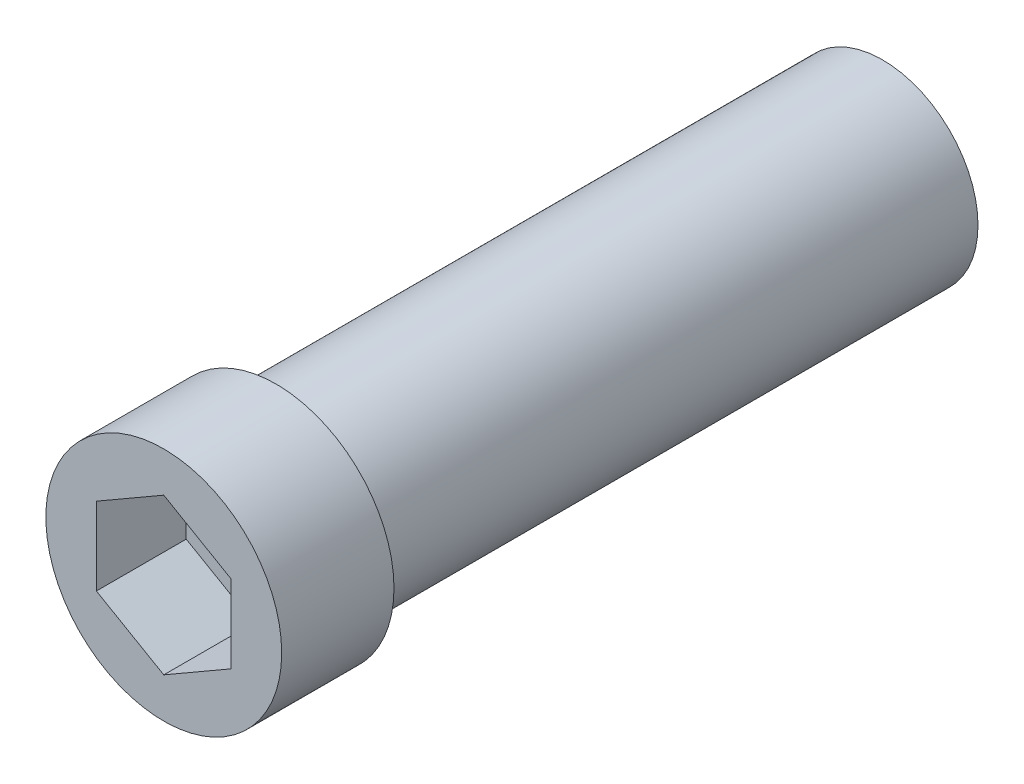
from build123d import *

# Parameters (mm, degrees)
SKETCH1_R           = 4.25
BOSS_EXTRUDE1_DEPTH = 27
SKETCH2_R           = 5.25
BOSS_EXTRUDE2_DEPTH = 5
SKETCH7_R           = 1.75
CUT_EXTRUDE4_DEPTH  = 33
CUT_EXTRUDE6_DEPTH  = 4


with BuildPart() as part:
    # Sketch1 → Boss-Extrude1 (new body)
    with BuildSketch(Plane.XY):
        Circle(SKETCH1_R)
    extrude(amount=BOSS_EXTRUDE1_DEPTH)

    # Sketch2 → Boss-Extrude2 (add)
    with BuildSketch(Plane.XY.offset(27)):
        Circle(SKETCH2_R)
    extrude(amount=BOSS_EXTRUDE2_DEPTH)

    # Sketch7 → Cut-Extrude4 (cut, through all)
    with BuildSketch(Plane.XY.offset(32)):
        Circle(SKETCH7_R)
    extrude(amount=-CUT_EXTRUDE4_DEPTH, mode=Mode.SUBTRACT)

    # Sketch9 → Cut-Extrude6 (cut)
    with BuildSketch(Plane.XY.offset(32)):
        Polygon((0, 3.464101615), (-3, 1.732050808), (-3, -1.732050808), (0, -3.464101615), (3, -1.732050808), (3, 1.732050808), align=None)
    extrude(amount=-CUT_EXTRUDE6_DEPTH, mode=Mode.SUBTRACT)


solid = part.part
